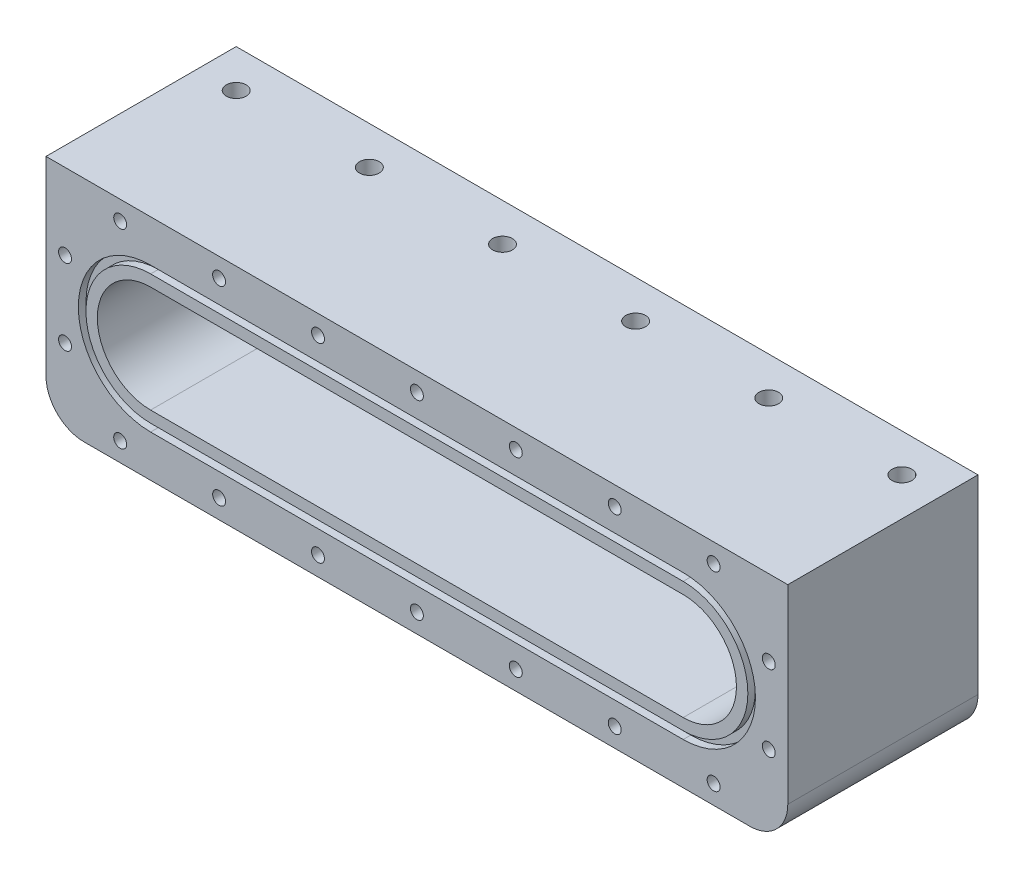
from build123d import *

# Parameters (mm, degrees)
SKETCH1_W           = 247.65
SKETCH1_H           = 63.5
BOSS_EXTRUDE1_DEPTH = 76.2
CUT_EXTRUDE1_DEPTH  = 57.15
SKETCH5_R           = 2.159
CUT_EXTRUDE3_DEPTH  = 6.35
SKETCH7_R           = 5.08
CUT_EXTRUDE5_DEPTH  = 25.4
FILLET1_R           = 12.7
CUT_EXTRUDE6_DEPTH  = 2.54
SKETCH9_R           = 3.302
CUT_EXTRUDE7_DEPTH  = 12.7


with BuildPart() as part:
    # Sketch1 → Boss-Extrude1 (new body)
    with BuildSketch(Plane(origin=(0, 0, 0), x_dir=(1, 0, 0), z_dir=(0, 1, 0))):
        Rectangle(SKETCH1_W, SKETCH1_H)
    extrude(amount=BOSS_EXTRUDE1_DEPTH)

    # Sketch2 → Cut-Extrude1 (cut)
    with BuildSketch(Plane.XY.offset(31.75)):
        with BuildLine():
            Line((-88.9, 55.88), (88.9, 55.88))
            ThreePointArc((88.9, 55.88), (106.68, 38.1), (88.9, 20.32))
            Line((88.9, 20.32), (-88.9, 20.32))
            ThreePointArc((-88.9, 20.32), (-106.68, 38.1), (-88.9, 55.88))
        make_face()
    extrude(amount=-CUT_EXTRUDE1_DEPTH, mode=Mode.SUBTRACT)

    # Sketch5 → Cut-Extrude3 (cut)
    with BuildSketch(Plane.XY.offset(31.75)):
        with Locations((0, 69.85)):
            Circle(SKETCH5_R)
        with Locations((33.02, 69.85)):
            Circle(SKETCH5_R)
        with Locations((66.04, 69.85)):
            Circle(SKETCH5_R)
        with Locations((-66.04, 69.85)):
            Circle(SKETCH5_R)
        with Locations((-33.02, 69.85)):
            Circle(SKETCH5_R)
        with Locations((-99.06, 69.85)):
            Circle(SKETCH5_R)
        with Locations((99.06, 69.85)):
            Circle(SKETCH5_R)
        with Locations((-99.06, 6.35)):
            Circle(SKETCH5_R)
        with Locations((-66.04, 6.35)):
            Circle(SKETCH5_R)
        with Locations((-33.02, 6.35)):
            Circle(SKETCH5_R)
        with Locations((0, 6.35)):
            Circle(SKETCH5_R)
        with Locations((33.02, 6.35)):
            Circle(SKETCH5_R)
        with Locations((66.04, 6.35)):
            Circle(SKETCH5_R)
        with Locations((99.06, 6.35)):
            Circle(SKETCH5_R)
        with Locations((-117.475, 50.8)):
            Circle(SKETCH5_R)
        with Locations((117.475, 50.8)):
            Circle(SKETCH5_R)
        with Locations((-117.475, 25.4)):
            Circle(SKETCH5_R)
        with Locations((117.475, 25.4)):
            Circle(SKETCH5_R)
    extrude(amount=-CUT_EXTRUDE3_DEPTH, mode=Mode.SUBTRACT)

    # Sketch7 → Cut-Extrude5 (cut)
    with BuildSketch(Plane(origin=(0, 0, 0), x_dir=(-1, 0, 0), z_dir=(0, -1, 0))):
        with Locations((-83.185, 15.24)):
            Circle(SKETCH7_R)
    extrude(amount=-CUT_EXTRUDE5_DEPTH, mode=Mode.SUBTRACT)

    # Fillet1
    fillet1_edges = [part.edges().sort_by_distance(p)[0] for p in [
        (-123.825, 0, 0),
        (123.825, 0, 0),
    ]]
    fillet(fillet1_edges, radius=FILLET1_R)

    # Sketch8 → Cut-Extrude6 (cut)
    with BuildSketch(Plane.XY.offset(31.75)):
        with BuildLine():
            Line((-88.9, 13.97), (88.9, 13.97))
            ThreePointArc((88.9, 13.97), (113.03, 38.1), (88.9, 62.23))
            Line((88.9, 62.23), (-88.9, 62.23))
            ThreePointArc((-88.9, 62.23), (-113.03, 38.1), (-88.9, 13.97))
        make_face()
        with BuildLine():
            ThreePointArc((88.9, 16.51), (110.49, 38.1), (88.9, 59.69))
            Line((88.9, 59.69), (-88.9, 59.69))
            ThreePointArc((-88.9, 59.69), (-110.49, 38.1), (-88.9, 16.51))
            Line((-88.9, 16.51), (88.9, 16.51))
        make_face(mode=Mode.SUBTRACT)
    extrude(amount=-CUT_EXTRUDE6_DEPTH, mode=Mode.SUBTRACT)

    # Sketch9 → Cut-Extrude7 (cut)
    with BuildSketch(Plane(origin=(0, 76.2, 44.45), x_dir=(-1, 0, 0), z_dir=(0, -1, 0))):
        with Locations((-111.125, 63.5)):
            Circle(SKETCH9_R)
        with Locations((-66.675, 63.5)):
            Circle(SKETCH9_R)
        with Locations((-22.225, 63.5)):
            Circle(SKETCH9_R)
        with Locations((22.225, 63.5)):
            Circle(SKETCH9_R)
        with Locations((66.675, 63.5)):
            Circle(SKETCH9_R)
        with Locations((111.125, 63.5)):
            Circle(SKETCH9_R)
    extrude(amount=CUT_EXTRUDE7_DEPTH, mode=Mode.SUBTRACT)


solid = part.part
